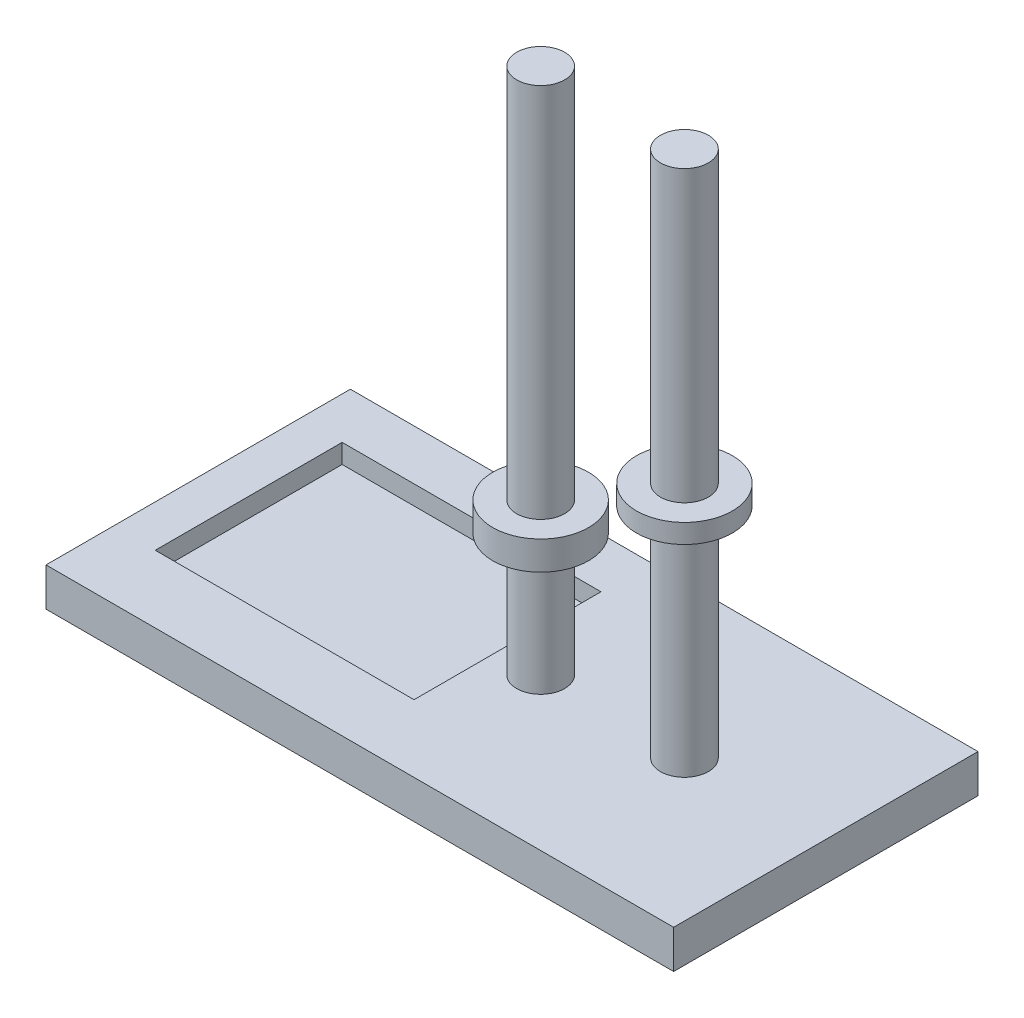
from build123d import *

# Parameters (mm, degrees)
SKETCH2_W           = 87.535593736
SKETCH2_H           = 41.754052132
BOSS_EXTRUDE1_DEPTH = 4
SKETCH1_R           = 2.5
BOSS_EXTRUDE2_DEPTH = 55
SKETCH4_R           = 5
BOSS_EXTRUDE3_DEPTH = 2
SKETCH5_W           = 87.535593736
SKETCH5_H           = 41.754052132
SKETCH5_W_2         = 65.477303461
SKETCH5_H_2         = 31.754052132
CUT_EXTRUDE5_DEPTH  = 10
SKETCH6_R           = 5
BOSS_EXTRUDE4_DEPTH = 3
SKETCH1_3_W         = 27
SKETCH1_3_H         = 19.5
CUT_EXTRUDE1_DEPTH  = 2


with BuildPart() as part:
    # Sketch2 → Boss-Extrude1 (new body)
    with BuildSketch(Plane(origin=(0, 0, 0), x_dir=(1, 0, 0), z_dir=(0, 1, 0))):
        Rectangle(SKETCH2_W, SKETCH2_H)
    extrude(amount=-BOSS_EXTRUDE1_DEPTH)

    # Sketch1 → Boss-Extrude2 (add)
    with BuildSketch(Plane(origin=(0, 0, 0), x_dir=(1, 0, 0), z_dir=(0, 1, 0))):
        with Locations((11.961031396, 0)):
            Circle(SKETCH1_R)
        with Locations((-3.038968604, 0)):
            Circle(SKETCH1_R)
    extrude(amount=BOSS_EXTRUDE2_DEPTH)

    # Sketch4 → Boss-Extrude3 (add)
    with BuildSketch(Plane(origin=(0, 24.8, 0), x_dir=(1, 0, 0), z_dir=(0, 1, 0))):
        with Locations((11.961031396, 0)):
            Circle(SKETCH4_R)
    extrude(amount=-BOSS_EXTRUDE3_DEPTH)

    # Sketch5 → Cut-Extrude5 (cut)
    with BuildSketch(Plane(origin=(0, 0, 0), x_dir=(1, 0, 0), z_dir=(0, 1, 0))):
        Rectangle(SKETCH5_W, SKETCH5_H)
        with Locations((-6.029145138, 0)):
            Rectangle(SKETCH5_W_2, SKETCH5_H_2, mode=Mode.SUBTRACT)
    extrude(amount=-CUT_EXTRUDE5_DEPTH, mode=Mode.SUBTRACT)

    # Sketch6 → Boss-Extrude4 (add)
    with BuildSketch(Plane(origin=(0, 15.8, 0), x_dir=(1, 0, 0), z_dir=(0, 1, 0))):
        with Locations((-3.038968604, 0)):
            Circle(SKETCH6_R)
    extrude(amount=-BOSS_EXTRUDE4_DEPTH)

    # Sketch1_3 → Cut-Extrude1 (cut)
    with BuildSketch(Plane(origin=(0, 0, 0), x_dir=(1, 0, 0), z_dir=(0, 1, 0))):
        with Locations((-20.892540318, 0.894456821)):
            Rectangle(SKETCH1_3_W, SKETCH1_3_H)
    extrude(amount=-CUT_EXTRUDE1_DEPTH, mode=Mode.SUBTRACT)


solid = part.part
